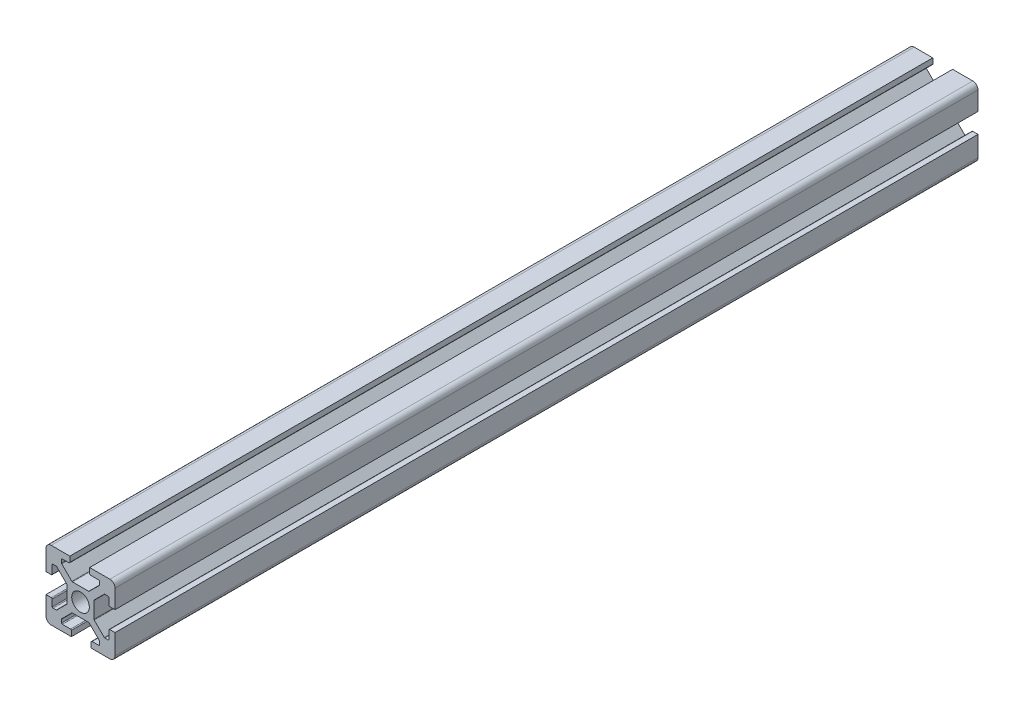
from build123d import *

# Parameters (mm, degrees)
SKETCH1_R           = 2.55
BOSS_EXTRUDE1_DEPTH = 250


with BuildPart() as part:
    # Sketch1 → Boss-Extrude1 (new body)
    with BuildSketch(Plane.XY):
        with BuildLine():
            Line((-8.5, -10), (-2.647623804, -10))
            Line((-2.647623804, -10), (-2.647623804, -8.45))
            ThreePointArc((-2.647623804, -8.45), (-2.720847109, -8.273223305), (-2.897623804, -8.2))
            Line((-2.897623804, -8.2), (-5.25, -8.2))
            ThreePointArc((-5.25, -8.2), (-5.426776695, -8.126776695), (-5.5, -7.95))
            Line((-5.5, -7.95), (-5.5, -7.053553391))
            ThreePointArc((-5.5, -7.053553391), (-5.480969883, -6.957882533), (-5.426776695, -6.876776695))
            Line((-5.426776695, -6.876776695), (-2.523223305, -3.973223305))
            ThreePointArc((-2.523223305, -3.973223305), (-2.442117467, -3.919030117), (-2.346446609, -3.9))
            Line((-2.346446609, -3.9), (2.346446609, -3.9))
            ThreePointArc((2.346446609, -3.9), (2.442117467, -3.919030117), (2.523223305, -3.973223305))
            Line((2.523223305, -3.973223305), (5.426776695, -6.876776695))
            ThreePointArc((5.426776695, -6.876776695), (5.480969883, -6.957882533), (5.5, -7.053553391))
            Line((5.5, -7.053553391), (5.5, -7.95))
            ThreePointArc((5.5, -7.95), (5.426776695, -8.126776695), (5.25, -8.2))
            Line((5.25, -8.2), (3.35, -8.2))
            ThreePointArc((3.35, -8.2), (3.173223305, -8.273223305), (3.1, -8.45))
            Line((3.1, -8.45), (3.1, -10))
            Line((3.1, -10), (8.5, -10))
            ThreePointArc((8.5, -10), (9.560660172, -9.560660172), (10, -8.5))
            Line((10, -8.5), (10, -2.647623804))
            Line((10, -2.647623804), (8.45, -2.647623804))
            ThreePointArc((8.45, -2.647623804), (8.273223305, -2.720847109), (8.2, -2.897623804))
            Line((8.2, -2.897623804), (8.2, -5.25))
            ThreePointArc((8.2, -5.25), (8.126776695, -5.426776695), (7.95, -5.5))
            Line((7.95, -5.5), (7.053553391, -5.5))
            ThreePointArc((7.053553391, -5.5), (6.957882533, -5.480969883), (6.876776695, -5.426776695))
            Line((6.876776695, -5.426776695), (3.973223305, -2.523223305))
            ThreePointArc((3.973223305, -2.523223305), (3.919030117, -2.442117467), (3.9, -2.346446609))
            Line((3.9, -2.346446609), (3.9, 2.346446609))
            ThreePointArc((3.9, 2.346446609), (3.919030117, 2.442117467), (3.973223305, 2.523223305))
            Line((3.973223305, 2.523223305), (6.876776695, 5.426776695))
            ThreePointArc((6.876776695, 5.426776695), (6.957882533, 5.480969883), (7.053553391, 5.5))
            Line((7.053553391, 5.5), (7.95, 5.5))
            ThreePointArc((7.95, 5.5), (8.126776695, 5.426776695), (8.2, 5.25))
            Line((8.2, 5.25), (8.2, 3.35))
            ThreePointArc((8.2, 3.35), (8.273223305, 3.173223305), (8.45, 3.1))
            Line((8.45, 3.1), (10, 3.1))
            Line((10, 3.1), (10, 8.5))
            ThreePointArc((10, 8.5), (9.560660172, 9.560660172), (8.5, 10))
            Line((8.5, 10), (2.647623804, 10))
            Line((2.647623804, 10), (2.647623804, 8.45))
            ThreePointArc((2.647623804, 8.45), (2.720847109, 8.273223305), (2.897623804, 8.2))
            Line((2.897623804, 8.2), (5.25, 8.2))
            ThreePointArc((5.25, 8.2), (5.426776695, 8.126776695), (5.5, 7.95))
            Line((5.5, 7.95), (5.5, 7.053553391))
            ThreePointArc((5.5, 7.053553391), (5.480969883, 6.957882533), (5.426776695, 6.876776695))
            Line((5.426776695, 6.876776695), (2.523223305, 3.973223305))
            ThreePointArc((2.523223305, 3.973223305), (2.442117467, 3.919030117), (2.346446609, 3.9))
            Line((2.346446609, 3.9), (-2.346446609, 3.9))
            ThreePointArc((-2.346446609, 3.9), (-2.442117467, 3.919030117), (-2.523223305, 3.973223305))
            Line((-2.523223305, 3.973223305), (-5.426776695, 6.876776695))
            ThreePointArc((-5.426776695, 6.876776695), (-5.480969883, 6.957882533), (-5.5, 7.053553391))
            Line((-5.5, 7.053553391), (-5.5, 7.95))
            ThreePointArc((-5.5, 7.95), (-5.426776695, 8.126776695), (-5.25, 8.2))
            Line((-5.25, 8.2), (-3.35, 8.2))
            ThreePointArc((-3.35, 8.2), (-3.173223305, 8.273223305), (-3.1, 8.45))
            Line((-3.1, 8.45), (-3.1, 10))
            Line((-3.1, 10), (-8.5, 10))
            ThreePointArc((-8.5, 10), (-9.560660172, 9.560660172), (-10, 8.5))
            Line((-10, 8.5), (-10, 2.647623804))
            Line((-10, 2.647623804), (-8.45, 2.647623804))
            ThreePointArc((-8.45, 2.647623804), (-8.273223305, 2.720847109), (-8.2, 2.897623804))
            Line((-8.2, 2.897623804), (-8.2, 5.25))
            ThreePointArc((-8.2, 5.25), (-8.126776695, 5.426776695), (-7.95, 5.5))
            Line((-7.95, 5.5), (-7.053553391, 5.5))
            ThreePointArc((-7.053553391, 5.5), (-6.957882533, 5.480969883), (-6.876776695, 5.426776695))
            Line((-6.876776695, 5.426776695), (-3.973223305, 2.523223305))
            ThreePointArc((-3.973223305, 2.523223305), (-3.919030117, 2.442117467), (-3.9, 2.346446609))
            Line((-3.9, 2.346446609), (-3.9, -2.346446609))
            ThreePointArc((-3.9, -2.346446609), (-3.919030117, -2.442117467), (-3.973223305, -2.523223305))
            Line((-3.973223305, -2.523223305), (-6.876776695, -5.426776695))
            ThreePointArc((-6.876776695, -5.426776695), (-6.957882533, -5.480969883), (-7.053553391, -5.5))
            Line((-7.053553391, -5.5), (-7.95, -5.5))
            ThreePointArc((-7.95, -5.5), (-8.126776695, -5.426776695), (-8.2, -5.25))
            Line((-8.2, -5.25), (-8.2, -3.35))
            ThreePointArc((-8.2, -3.35), (-8.273223305, -3.173223305), (-8.45, -3.1))
            Line((-8.45, -3.1), (-10, -3.1))
            Line((-10, -3.1), (-10, -8.5))
            ThreePointArc((-10, -8.5), (-9.560660172, -9.560660172), (-8.5, -10))
        make_face()
        Circle(SKETCH1_R, mode=Mode.SUBTRACT)
    extrude(amount=BOSS_EXTRUDE1_DEPTH)


solid = part.part
